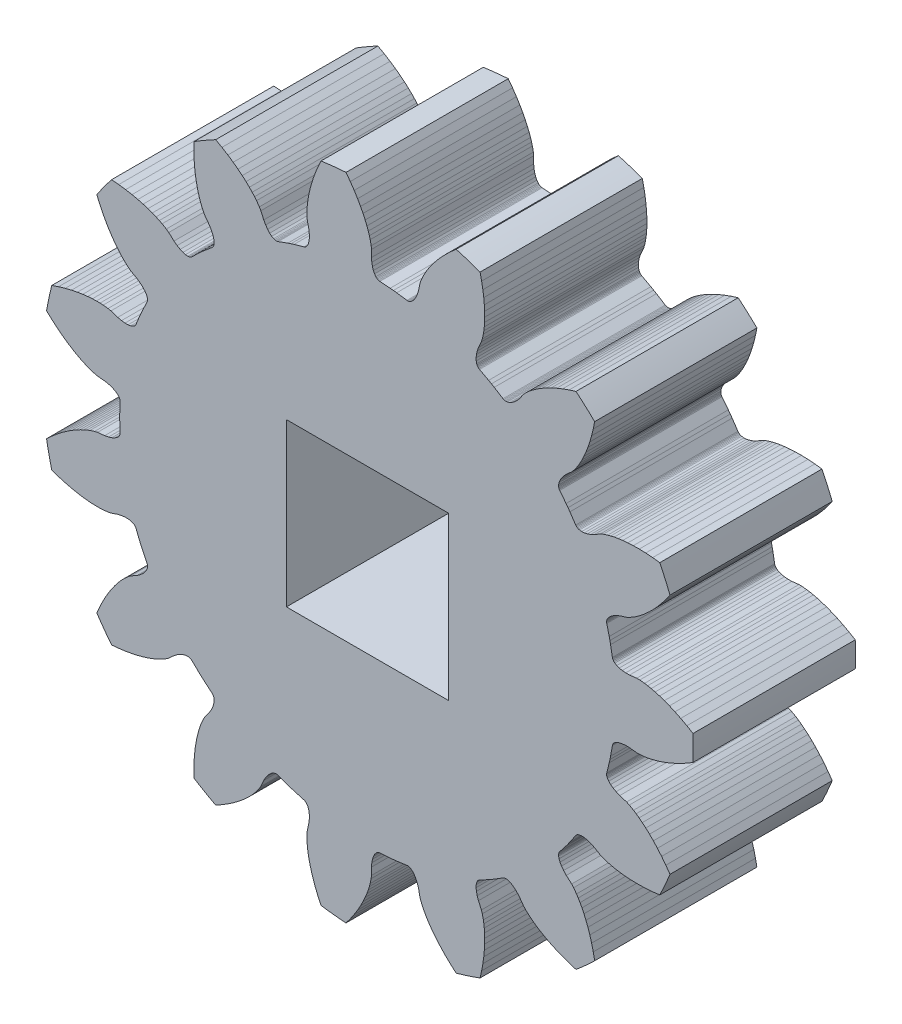
from build123d import *

# Parameters (mm, degrees)
BOSS_EXTRUDE1_DEPTH     = 3.175
CUT_EXTRUDE1_DEPTH      = 19.289183037
CUT_EXTRUDE1_DEPTH_BACK = 19.289183037
SKETCH2_W               = 6.35
SKETCH2_H               = 6.35


with BuildPart() as part:
    # Model → Boss-Extrude1 (new, symmetric)
    with BuildSketch(Plane.XY):
        with BuildLine():
            Line((11.6767396, 4.5035235), (11.5102774, 4.2884543))
            Line((11.5102774, 4.2884543), (11.3474436, 4.0953698))
            Line((11.3474436, 4.0953698), (11.189078, 3.9227721))
            Line((11.189078, 3.9227721), (11.0381832, 3.7714935))
            Line((11.0381832, 3.7714935), (10.8924568, 3.6371189))
            Line((10.8924568, 3.6371189), (10.7549211, 3.520628))
            Line((10.7549211, 3.520628), (10.6294039, 3.4230594))
            Line((10.6294039, 3.4230594), (10.5151057, 3.3415851))
            Line((10.5151057, 3.3415851), (10.4118689, 3.2743006))
            Line((10.4118689, 3.2743006), (10.2465352, 3.1803221))
            Line((10.2465352, 3.1803221), (10.1399378, 3.1308686))
            Line((10.1399378, 3.1308686), (9.8729831, 3.0466553))
            Line((9.8729831, 3.0466553), (9.731807, 2.9862021))
            Line((9.731807, 2.9862021), (9.6130244, 2.9201014))
            Line((9.6130244, 2.9201014), (9.516822, 2.8501205))
            Line((9.516822, 2.8501205), (9.4432844, 2.7780258))
            Line((9.4432844, 2.7780258), (9.3923921, 2.7055918))
            Line((9.3923921, 2.7055918), (9.3753911, 2.6698051))
            Line((9.3753911, 2.6698051), (9.3639924, 2.6345957))
            Line((9.3639924, 2.6345957), (9.3581623, 2.6001713))
            Line((9.3581623, 2.6001713), (9.3578605, 2.5667687))
            Line((9.3578605, 2.5667687), (9.3630336, 2.5345911))
            Line((9.3630336, 2.5345911), (9.460687, 2.1414942))
            Line((9.460687, 2.1414942), (9.4880317, 2.0167434))
            Line((9.4880317, 2.0167434), (9.5137918, 1.8916558))
            Line((9.5137918, 1.8916558), (9.5844679, 1.4928247))
            Line((9.5844679, 1.4928247), (9.5928298, 1.4613249))
            Line((9.5928298, 1.4613249), (9.6066916, 1.4309328))
            Line((9.6066916, 1.4309328), (9.6260194, 1.4018559))
            Line((9.6260194, 1.4018559), (9.6507535, 1.3743268))
            Line((9.6507535, 1.3743268), (9.6808405, 1.3485489))
            Line((9.6808405, 1.3485489), (9.7567944, 1.303077))
            Line((9.7567944, 1.303077), (9.853298, 1.2671256))
            Line((9.853298, 1.2671256), (9.969647, 1.2423239))
            Line((9.969647, 1.2423239), (10.1050459, 1.2302511))
            Line((10.1050459, 1.2302511), (10.2586052, 1.2324459))
            Line((10.2586052, 1.2324459), (10.5367331, 1.2640935))
            Line((10.5367331, 1.2640935), (10.6542293, 1.2622725))
            Line((10.6542293, 1.2622725), (10.8434936, 1.2436662))
            Line((10.8434936, 1.2436662), (10.9651721, 1.2241889))
            Line((10.9651721, 1.2241889), (11.1027273, 1.1962477))
            Line((11.1027273, 1.1962477), (11.2570777, 1.1581668))
            Line((11.2570777, 1.1581668), (11.4301039, 1.1076879))
            Line((11.4301039, 1.1076879), (11.6178867, 1.0442028))
            Line((11.6178867, 1.0442028), (11.8172666, 0.9673774))
            Line((11.8172666, 0.9673774), (12.0321425, 0.8741146))
            Line((12.0321425, 0.8741146), (12.2594331, 0.7639537))
            Line((12.2594331, 0.7639537), (12.4989804, 0.6351845))
            Line((12.4989804, 0.6351845), (12.740472, 0.4919755))
            ThreePointArc((12.740472, 0.4919755), (12.749967296, 0), (12.740472, -0.4919755))
            Line((12.740472, -0.4919755), (12.4989804, -0.6351845))
            Line((12.4989804, -0.6351845), (12.2594331, -0.7639537))
            Line((12.2594331, -0.7639537), (12.0321425, -0.8741146))
            Line((12.0321425, -0.8741146), (11.8172666, -0.9673774))
            Line((11.8172666, -0.9673774), (11.6178867, -1.0442028))
            Line((11.6178867, -1.0442028), (11.4301039, -1.1076879))
            Line((11.4301039, -1.1076879), (11.2570777, -1.1581668))
            Line((11.2570777, -1.1581668), (11.1027273, -1.1962477))
            Line((11.1027273, -1.1962477), (10.9651721, -1.2241889))
            Line((10.9651721, -1.2241889), (10.8434936, -1.2436662))
            Line((10.8434936, -1.2436662), (10.6542293, -1.2622725))
            Line((10.6542293, -1.2622725), (10.5367331, -1.2640935))
            Line((10.5367331, -1.2640935), (10.2586052, -1.2324459))
            Line((10.2586052, -1.2324459), (10.1050459, -1.2302511))
            Line((10.1050459, -1.2302511), (9.969647, -1.2423239))
            Line((9.969647, -1.2423239), (9.853298, -1.2671256))
            Line((9.853298, -1.2671256), (9.7567944, -1.303077))
            Line((9.7567944, -1.303077), (9.6808405, -1.3485489))
            Line((9.6808405, -1.3485489), (9.6507535, -1.3743268))
            Line((9.6507535, -1.3743268), (9.6260194, -1.4018559))
            Line((9.6260194, -1.4018559), (9.6066916, -1.4309328))
            Line((9.6066916, -1.4309328), (9.5928298, -1.4613249))
            Line((9.5928298, -1.4613249), (9.5844679, -1.4928247))
            Line((9.5844679, -1.4928247), (9.5137918, -1.8916558))
            Line((9.5137918, -1.8916558), (9.4880317, -2.0167434))
            Line((9.4880317, -2.0167434), (9.460687, -2.1414942))
            Line((9.460687, -2.1414942), (9.3630336, -2.5345911))
            Line((9.3630336, -2.5345911), (9.3578605, -2.5667687))
            Line((9.3578605, -2.5667687), (9.3581623, -2.6001713))
            Line((9.3581623, -2.6001713), (9.3639924, -2.6345957))
            Line((9.3639924, -2.6345957), (9.3753911, -2.6698051))
            Line((9.3753911, -2.6698051), (9.3923921, -2.7055918))
            Line((9.3923921, -2.7055918), (9.4432844, -2.7780258))
            Line((9.4432844, -2.7780258), (9.516822, -2.8501205))
            Line((9.516822, -2.8501205), (9.6130244, -2.9201014))
            Line((9.6130244, -2.9201014), (9.731807, -2.9862021))
            Line((9.731807, -2.9862021), (9.8729831, -3.0466553))
            Line((9.8729831, -3.0466553), (10.1399378, -3.1308686))
            Line((10.1399378, -3.1308686), (10.2465352, -3.1803221))
            Line((10.2465352, -3.1803221), (10.4118689, -3.2743006))
            Line((10.4118689, -3.2743006), (10.5151057, -3.3415851))
            Line((10.5151057, -3.3415851), (10.6294039, -3.4230594))
            Line((10.6294039, -3.4230594), (10.7549211, -3.520628))
            Line((10.7549211, -3.520628), (10.8924568, -3.6371189))
            Line((10.8924568, -3.6371189), (11.0381832, -3.7714935))
            Line((11.0381832, -3.7714935), (11.189078, -3.9227721))
            Line((11.189078, -3.9227721), (11.3474436, -4.0953698))
            Line((11.3474436, -4.0953698), (11.5102774, -4.2884543))
            Line((11.5102774, -4.2884543), (11.6767396, -4.5035235))
            Line((11.6767396, -4.5035235), (11.8391048, -4.7325748))
            ThreePointArc((11.8391048, -4.7325748), (11.647674735, -5.185878885), (11.4388959, -5.6314588))
            Line((11.4388959, -5.6314588), (11.160034, -5.6640632))
            Line((11.160034, -5.6640632), (10.8888215, -5.6842671))
            Line((10.8888215, -5.6842671), (10.6363747, -5.6924567))
            Line((10.6363747, -5.6924567), (10.4021424, -5.6902585))
            Line((10.4021424, -5.6902585), (10.1887521, -5.679347))
            Line((10.1887521, -5.679347), (9.9913823, -5.6609653))
            Line((9.9913823, -5.6609653), (9.8127834, -5.636704))
            Line((9.8127834, -5.636704), (9.6562884, -5.6087127))
            Line((9.6562884, -5.6087127), (9.5192607, -5.5782895))
            Line((9.5192607, -5.5782895), (9.4001797, -5.5465918))
            Line((9.4001797, -5.5465918), (9.2197103, -5.4866088))
            Line((9.2197103, -5.4866088), (9.1116315, -5.4404823))
            Line((9.1116315, -5.4404823), (8.8704213, -5.298446))
            Line((8.8704213, -5.298446), (8.7310306, -5.2339828))
            Line((8.7310306, -5.2339828), (8.6024271, -5.1899402))
            Line((8.6024271, -5.1899402), (8.4860492, -5.1652742))
            Line((8.4860492, -5.1652742), (8.3832661, -5.1588659))
            Line((8.3832661, -5.1588659), (8.2953836, -5.1695133))
            Line((8.2953836, -5.1695133), (8.257413, -5.1808251))
            Line((8.257413, -5.1808251), (8.2236201, -5.1959139))
            Line((8.2236201, -5.1959139), (8.1941367, -5.2146157))
            Line((8.1941367, -5.2146157), (8.1691117, -5.2367421))
            Line((8.1691117, -5.2367421), (8.1486606, -5.2621176))
            Line((8.1486606, -5.2621176), (7.9218756, -5.5977213))
            Line((7.9218756, -5.5977213), (7.8474648, -5.7015169))
            Line((7.8474648, -5.7015169), (7.7717435, -5.8043604))
            Line((7.7717435, -5.8043604), (7.5226458, -6.123753))
            Line((7.5226458, -6.123753), (7.5048321, -6.1510446))
            Line((7.5048321, -6.1510446), (7.4915217, -6.1816822))
            Line((7.4915217, -6.1816822), (7.4828461, -6.2155018))
            Line((7.4828461, -6.2155018), (7.4789384, -6.2523034))
            Line((7.4789384, -6.2523034), (7.4799138, -6.2919111))
            Line((7.4799138, -6.2919111), (7.4969447, -6.3787826))
            Line((7.4969447, -6.3787826), (7.5348011, -6.4745549))
            Line((7.5348011, -6.4745549), (7.5942226, -6.5776146))
            Line((7.5942226, -6.5776146), (7.6758502, -6.6863139))
            Line((7.6758502, -6.6863139), (7.7802325, -6.7989622))
            Line((7.7802325, -6.7989622), (7.9898551, -6.984475))
            Line((7.9898551, -6.984475), (8.0671222, -7.0730102))
            Line((8.0671222, -7.0730102), (8.1799375, -7.2261111))
            Line((8.1799375, -7.2261111), (8.246882, -7.3295686))
            Line((8.246882, -7.3295686), (8.31816, -7.4504884))
            Line((8.31816, -7.4504884), (8.3931409, -7.5906742))
            Line((8.3931409, -7.5906742), (8.4714049, -7.7530347))
            Line((8.4714049, -7.7530347), (8.5498775, -7.9350643))
            Line((8.5498775, -7.9350643), (8.6261962, -8.1346387))
            Line((8.6261962, -8.1346387), (8.7006686, -8.3567276))
            Line((8.7006686, -8.3567276), (8.7708902, -8.5993495))
            Line((8.7708902, -8.5993495), (8.8354844, -8.8635313))
            Line((8.8354844, -8.8635313), (8.8906488, -9.13882))
            ThreePointArc((8.8906488, -9.13882), (8.531393343, -9.47507223), (8.1594307, -9.7972117))
            Line((8.1594307, -9.7972117), (7.8914163, -9.713574))
            Line((7.8914163, -9.713574), (7.6354337, -9.6217191))
            Line((7.6354337, -9.6217191), (7.4014811, -9.5265213))
            Line((7.4014811, -9.5265213), (7.1883932, -9.4292423))
            Line((7.1883932, -9.4292423), (6.9978897, -9.3324805))
            Line((6.9978897, -9.3324805), (6.8250599, -9.2354105))
            Line((6.8250599, -9.2354105), (6.6717696, -9.1406039))
            Line((6.6717696, -9.1406039), (6.5401894, -9.0513803))
            Line((6.5401894, -9.0513803), (6.4273826, -8.9678532))
            Line((6.4273826, -8.9678532), (6.3314894, -8.8904613))
            Line((6.3314894, -8.8904613), (6.1910196, -8.7622605))
            Line((6.1910196, -8.7622605), (6.1110461, -8.6761623))
            Line((6.1110461, -8.6761623), (5.948461, -8.4482966))
            Line((5.948461, -8.4482966), (5.8473407, -8.3327113))
            Line((5.8473407, -8.3327113), (5.7477694, -8.2401686))
            Line((5.7477694, -8.2401686), (5.6514854, -8.1702999))
            Line((5.6514854, -8.1702999), (5.5601949, -8.12264))
            Line((5.5601949, -8.12264), (5.4755795, -8.0966219))
            Line((5.4755795, -8.0966219), (5.4362907, -8.0915117))
            Line((5.4362907, -8.0915117), (5.3992822, -8.0915512))
            Line((5.3992822, -8.0915512), (5.3647411, -8.0966441))
            Line((5.3647411, -8.0966441), (5.33288, -8.1066791))
            Line((5.33288, -8.1066791), (5.3038758, -8.1215424))
            Line((5.3038758, -8.1215424), (4.9601951, -8.3358899))
            Line((4.9601951, -8.3358899), (4.85, -8.4004464))
            Line((4.85, -8.4004464), (4.7389949, -8.4635999))
            Line((4.7389949, -8.4635999), (4.3815242, -8.6540624))
            Line((4.3815242, -8.6540624), (4.35415, -8.6717491))
            Line((4.35415, -8.6717491), (4.3295289, -8.6943241))
            Line((4.3295289, -8.6943241), (4.3078478, -8.7216912))
            Line((4.3078478, -8.7216912), (4.2893093, -8.7537217))
            Line((4.2893093, -8.7537217), (4.2740905, -8.7903019))
            Line((4.2740905, -8.7903019), (4.2543151, -8.87659))
            Line((4.2543151, -8.87659), (4.2499446, -8.9794799))
            Line((4.2499446, -8.9794799), (4.2623106, -9.0977986))
            Line((4.2623106, -9.0977986), (4.2926693, -9.2303013))
            Line((4.2926693, -9.2303013), (4.342209, -9.3756666))
            Line((4.342209, -9.3756666), (4.4582539, -9.6304023))
            Line((4.4582539, -9.6304023), (4.4928304, -9.7427105))
            Line((4.4928304, -9.7427105), (4.5336206, -9.9284613))
            Line((4.5336206, -9.9284613), (4.5526974, -10.0502032))
            Line((4.5526974, -10.0502032), (4.5686306, -10.1896603))
            Line((4.5686306, -10.1896603), (4.5801104, -10.3482239))
            Line((4.5801104, -10.3482239), (4.5855701, -10.5283805))
            Line((4.5855701, -10.5283805), (4.5832203, -10.7265905))
            Line((4.5832203, -10.7265905), (4.5717668, -10.9399523))
            Line((4.5717668, -10.9399523), (4.5494689, -11.1731313))
            Line((4.5494689, -11.1731313), (4.5149363, -11.4233391))
            Line((4.5149363, -11.4233391), (4.4664937, -11.690954))
            Line((4.4664937, -11.690954), (4.4049189, -11.9648801))
            ThreePointArc((4.4049189, -11.9648801), (3.939956558, -12.125939465), (3.4691258, -12.2689377))
            Line((3.4691258, -12.2689377), (3.258301, -12.0835196))
            Line((3.258301, -12.0835196), (3.06181, -11.8954884))
            Line((3.06181, -11.8954884), (2.8868041, -11.7133638))
            Line((2.8868041, -11.7133638), (2.7317056, -11.5378244))
            Line((2.7317056, -11.5378244), (2.5970286, -11.3719433))
            Line((2.5970286, -11.3719433), (2.4786226, -11.2129692))
            Line((2.4786226, -11.2129692), (2.3771463, -11.0640104))
            Line((2.3771463, -11.0640104), (2.2932323, -10.9289821))
            Line((2.2932323, -10.9289821), (2.2241517, -10.8067936))
            Line((2.2241517, -10.8067936), (2.168027, -10.6970892))
            Line((2.168027, -10.6970892), (2.0918454, -10.5228378))
            Line((2.0918454, -10.5228378), (2.0538053, -10.411655))
            Line((2.0538053, -10.411655), (1.9979577, -10.1373601))
            Line((1.9979577, -10.1373601), (1.9525926, -9.9906383))
            Line((1.9525926, -9.9906383), (1.8992701, -9.865597))
            Line((1.8992701, -9.865597), (1.8397285, -9.7626066))
            Line((1.8397285, -9.7626066), (1.7757154, -9.6819359))
            Line((1.7757154, -9.6819359), (1.708998, -9.623751))
            Line((1.708998, -9.623751), (1.6751844, -9.6031024))
            Line((1.6751844, -9.6031024), (1.6413594, -9.5880858))
            Line((1.6413594, -9.5880858), (1.607733, -9.5786892))
            Line((1.607733, -9.5786892), (1.5745448, -9.5748975))
            Line((1.5745448, -9.5748975), (1.5420028, -9.5766789))
            Line((1.5420028, -9.5766789), (1.1408518, -9.6327075))
            Line((1.1408518, -9.6327075), (1.0139261, -9.6468624))
            Line((1.0139261, -9.6468624), (0.886831, -9.6594062))
            Line((0.886831, -9.6594062), (0.4827972, -9.6880059))
            Line((0.4827972, -9.6880059), (0.4505959, -9.6930293))
            Line((0.4505959, -9.6930293), (0.4189213, -9.7036383))
            Line((0.4189213, -9.7036383), (0.3879834, -9.7198209))
            Line((0.3879834, -9.7198209), (0.3580197, -9.7415419))
            Line((0.3580197, -9.7415419), (0.3292381, -9.7687696))
            Line((0.3292381, -9.7687696), (0.2760759, -9.8395543))
            Line((0.2760759, -9.8395543), (0.230234, -9.9317713))
            Line((0.230234, -9.9317713), (0.1934065, -10.0448905))
            Line((0.1934065, -10.0448905), (0.1672468, -10.1782857))
            Line((0.1672468, -10.1782857), (0.1533782, -10.3312332))
            Line((0.1533782, -10.3312332), (0.1557801, -10.6111455))
            Line((0.1557801, -10.6111455), (0.1416874, -10.7278077))
            Line((0.1416874, -10.7278077), (0.1033995, -10.9140903))
            Line((0.1033995, -10.9140903), (0.0713101, -11.0330664))
            Line((0.0713101, -11.0330664), (0.0291435, -11.1669474))
            Line((0.0291435, -11.1669474), (-0.0248628, -11.3164717))
            Line((-0.0248628, -11.3164717), (-0.0931514, -11.4832735))
            Line((-0.0931514, -11.4832735), (-0.1759173, -11.6633916))
            Line((-0.1759173, -11.6633916), (-0.2731627, -11.8536488))
            Line((-0.2731627, -11.8536488), (-0.3883753, -12.0575991))
            Line((-0.3883753, -12.0575991), (-0.521691, -12.2721296))
            Line((-0.521691, -12.2721296), (-0.6747944, -12.4969046))
            Line((-0.6747944, -12.4969046), (-0.8424615, -12.7221038))
            ThreePointArc((-0.8424615, -12.7221038), (-1.332734479, -12.680121632), (-1.8210224, -12.6192529))
            Line((-1.8210224, -12.6192529), (-1.9382041, -12.3641149))
            Line((-1.9382041, -12.3641149), (-2.0412284, -12.1124198))
            Line((-2.0412284, -12.1124198), (-2.1270275, -11.8748593))
            Line((-2.1270275, -11.8748593), (-2.1973187, -11.6514119))
            Line((-2.1973187, -11.6514119), (-2.2528824, -11.4450938))
            Line((-2.2528824, -11.4450938), (-2.296391, -11.2517037))
            Line((-2.296391, -11.2517037), (-2.3285073, -11.0743489))
            Line((-2.3285073, -11.0743489), (-2.3502456, -10.9168635))
            Line((-2.3502456, -10.9168635), (-2.3636553, -10.7771412))
            Line((-2.3636553, -10.7771412), (-2.370307, -10.6540933))
            Line((-2.370307, -10.6540933), (-2.3690279, -10.4639209))
            Line((-2.3690279, -10.4639209), (-2.3585571, -10.346878))
            Line((-2.3585571, -10.346878), (-2.2980106, -10.0735819))
            Line((-2.2980106, -10.0735819), (-2.2797766, -9.9210931))
            Line((-2.2797766, -9.9210931), (-2.2776302, -9.7851741))
            Line((-2.2776302, -9.7851741), (-2.2901342, -9.6668699))
            Line((-2.2901342, -9.6668699), (-2.3158013, -9.5671371))
            Line((-2.3158013, -9.5671371), (-2.3530848, -9.4868461))
            Line((-2.3530848, -9.4868461), (-2.3755765, -9.4542294))
            Line((-2.3755765, -9.4542294), (-2.4003694, -9.4267532))
            Line((-2.4003694, -9.4267532), (-2.4272667, -9.4044919))
            Line((-2.4272667, -9.4044919), (-2.4560434, -9.3875292))
            Line((-2.4560434, -9.3875292), (-2.4864966, -9.3759205))
            Line((-2.4864966, -9.3759205), (-2.8757551, -9.2639424))
            Line((-2.8757551, -9.2639424), (-2.9974648, -9.2252482))
            Line((-2.9974648, -9.2252482), (-3.118674, -9.1850133))
            Line((-3.118674, -9.1850133), (-3.4994098, -9.0468051))
            Line((-3.4994098, -9.0468051), (-3.5308704, -9.0382968))
            Line((-3.5308704, -9.0382968), (-3.5641216, -9.0351054))
            Line((-3.5641216, -9.0351054), (-3.5989669, -9.0373053))
            Line((-3.5989669, -9.0373053), (-3.6351748, -9.0449611))
            Line((-3.6351748, -9.0449611), (-3.6725426, -9.0581283))
            Line((-3.6725426, -9.0581283), (-3.7498994, -9.1011703))
            Line((-3.7498994, -9.1011703), (-3.8292861, -9.1667692))
            Line((-3.8292861, -9.1667692), (-3.9089394, -9.2551296))
            Line((-3.9089394, -9.2551296), (-3.9870942, -9.366352))
            Line((-3.9870942, -9.366352), (-4.0619732, -9.5004357))
            Line((-4.0619732, -9.5004357), (-4.1736295, -9.7571253))
            Line((-4.1736295, -9.7571253), (-4.2339546, -9.8579694))
            Line((-4.2339546, -9.8579694), (-4.3447003, -10.012574))
            Line((-4.3447003, -10.012574), (-4.4224073, -10.1082121))
            Line((-4.4224073, -10.1082121), (-4.5153828, -10.2133678))
            Line((-4.5153828, -10.2133678), (-4.625537, -10.3279987))
            Line((-4.625537, -10.3279987), (-4.7557661, -10.4526043))
            Line((-4.7557661, -10.4526043), (-4.9046372, -10.5834864))
            Line((-4.9046372, -10.5834864), (-5.0708599, -10.7177417))
            Line((-5.0708599, -10.7177417), (-5.2590658, -10.8571984))
            Line((-5.2590658, -10.8571984), (-5.4681133, -10.9989574))
            Line((-5.4681133, -10.9989574), (-5.6994043, -11.1420268))
            Line((-5.6994043, -11.1420268), (-5.9441727, -11.2795602))
            ThreePointArc((-5.9441727, -11.2795602), (-6.374983648, -11.041795618), (-6.7962993, -10.7875847))
            Line((-6.7962993, -10.7875847), (-6.7995761, -10.5068423))
            Line((-6.7995761, -10.5068423), (-6.7913199, -10.2350037))
            Line((-6.7913199, -10.2350037), (-6.7730767, -9.9830838))
            Line((-6.7730767, -9.9830838), (-6.7464067, -9.7503643))
            Line((-6.7464067, -9.7503643), (-6.7132495, -9.5392836))
            Line((-6.7132495, -9.5392836), (-6.6743378, -9.3449164))
            Line((-6.6743378, -9.3449164), (-6.6315407, -9.1698319))
            Line((-6.6315407, -9.1698319), (-6.5873446, -9.0171201))
            Line((-6.5873446, -9.0171201), (-6.5427648, -8.8840231))
            Line((-6.5427648, -8.8840231), (-6.4987933, -8.7689078))
            Line((-6.4987933, -8.7689078), (-6.4202747, -8.5956969))
            Line((-6.4202747, -8.5956969), (-6.3631036, -8.4930318))
            Line((-6.3631036, -8.4930318), (-6.196632, -8.2679898))
            Line((-6.196632, -8.2679898), (-6.1179517, -8.1361009))
            Line((-6.1179517, -8.1361009), (-6.0607076, -8.0128056))
            Line((-6.0607076, -8.0128056), (-6.0240119, -7.8996436))
            Line((-6.0240119, -7.8996436), (-6.006895, -7.7980933))
            Line((-6.006895, -7.7980933), (-6.0082979, -7.7095793))
            Line((-6.0082979, -7.7095793), (-6.0155787, -7.6706343))
            Line((-6.0155787, -7.6706343), (-6.0270525, -7.6354494))
            Line((-6.0270525, -7.6354494), (-6.04257, -7.6041726))
            Line((-6.04257, -7.6041726), (-6.0619594, -7.5769719))
            Line((-6.0619594, -7.5769719), (-6.0850581, -7.5539803))
            Line((-6.0850581, -7.5539803), (-6.3951179, -7.2933575))
            Line((-6.3951179, -7.2933575), (-6.4905669, -7.2085048))
            Line((-6.4905669, -7.2085048), (-6.5849319, -7.1224482))
            Line((-6.5849319, -7.1224482), (-6.8765371, -6.8413295))
            Line((-6.8765371, -6.8413295), (-6.9018171, -6.8207606))
            Line((-6.9018171, -6.8207606), (-6.9308956, -6.8043206))
            Line((-6.9308956, -6.8043206), (-6.9636231, -6.7921575))
            Line((-6.9636231, -6.7921575), (-6.9998146, -6.7844243))
            Line((-6.9998146, -6.7844243), (-7.0393073, -6.7812543))
            Line((-7.0393073, -6.7812543), (-7.1274831, -6.7891113))
            Line((-7.1274831, -6.7891113), (-7.2266878, -6.8167494))
            Line((-7.2266878, -6.8167494), (-7.3353942, -6.8650727))
            Line((-7.3353942, -6.8650727), (-7.4520304, -6.934891))
            Line((-7.4520304, -6.934891), (-7.5749725, -7.0269265))
            Line((-7.5749725, -7.0269265), (-7.7813806, -7.2160094))
            Line((-7.7813806, -7.2160094), (-7.8775074, -7.2835987))
            Line((-7.8775074, -7.2835987), (-8.041562, -7.3797927))
            Line((-8.041562, -7.3797927), (-8.1514504, -7.4355561))
            Line((-8.1514504, -7.4355561), (-8.2791584, -7.4938041))
            Line((-8.2791584, -7.4938041), (-8.4264138, -7.5537209))
            Line((-8.4264138, -7.5537209), (-8.5960657, -7.6145848))
            Line((-8.5960657, -7.6145848), (-8.7853008, -7.6736003))
            Line((-8.7853008, -7.6736003), (-8.9917593, -7.7286398))
            Line((-8.9917593, -7.7286398), (-9.2204161, -7.7794895))
            Line((-9.2204161, -7.7794895), (-9.469049, -7.8239655))
            Line((-9.469049, -7.8239655), (-9.7385355, -7.8605914))
            Line((-9.7385355, -7.8605914), (-10.0180824, -7.8866781))
            ThreePointArc((-10.0180824, -7.8866781), (-10.314940206, -7.494242745), (-10.5964343, -7.090645))
            Line((-10.5964343, -7.090645), (-10.4852396, -6.8328413))
            Line((-10.4852396, -6.8328413), (-10.3671305, -6.5878625))
            Line((-10.3671305, -6.5878625), (-10.2479995, -6.3651424))
            Line((-10.2479995, -6.3651424), (-10.1289796, -6.1633903))
            Line((-10.1289796, -6.1633903), (-10.0128348, -5.9840447))
            Line((-10.0128348, -5.9840447), (-9.8982309, -5.8223082))
            Line((-9.8982309, -5.8223082), (-9.7879206, -5.6797677))
            Line((-9.7879206, -5.6797677), (-9.6854319, -5.5582347))
            Line((-9.6854319, -5.5582347), (-9.5905708, -5.4547768))
            Line((-9.5905708, -5.4547768), (-9.5035793, -5.3674986))
            Line((-9.5035793, -5.3674986), (-9.3613977, -5.2411989))
            Line((-9.3613977, -5.2411989), (-9.2674116, -5.1706632))
            Line((-9.2674116, -5.1706632), (-9.0237995, -5.0327872))
            Line((-9.0237995, -5.0327872), (-8.8982773, -4.9443029))
            Line((-8.8982773, -4.9443029), (-8.7958336, -4.8549503))
            Line((-8.7958336, -4.8549503), (-8.7162832, -4.7664971))
            Line((-8.7162832, -4.7664971), (-8.6593419, -4.6806884))
            Line((-8.6593419, -4.6806884), (-8.6246217, -4.5992563))
            Line((-8.6246217, -4.5992563), (-8.6154326, -4.5607168))
            Line((-8.6154326, -4.5607168), (-8.6116035, -4.523907))
            Line((-8.6116035, -4.523907), (-8.613058, -4.4890227))
            Line((-8.613058, -4.4890227), (-8.6197076, -4.4562872))
            Line((-8.6197076, -4.4562872), (-8.6314578, -4.4258883))
            Line((-8.6314578, -4.4258883), (-8.8087066, -4.0616849))
            Line((-8.8087066, -4.0616849), (-8.8613909, -3.9453454))
            Line((-8.8613909, -3.9453454), (-8.9125953, -3.8283471))
            Line((-8.9125953, -3.8283471), (-9.0646486, -3.4529259))
            Line((-9.0646486, -3.4529259), (-9.0793769, -3.4238529))
            Line((-9.0793769, -3.4238529), (-9.0992547, -3.397007))
            Line((-9.0992547, -3.397007), (-9.1242055, -3.3725839))
            Line((-9.1242055, -3.3725839), (-9.1541228, -3.350799))
            Line((-9.1541228, -3.350799), (-9.1889118, -3.3318398))
            Line((-9.1889118, -3.3318398), (-9.2726601, -3.3031533))
            Line((-9.2726601, -3.3031533), (-9.3745296, -3.2880517))
            Line((-9.3745296, -3.2880517), (-9.4934927, -3.2879823))
            Line((-9.4934927, -3.2879823), (-9.6284428, -3.3043244))
            Line((-9.6284428, -3.3043244), (-9.7781902, -3.3383979))
            Line((-9.7781902, -3.3383979), (-10.0436604, -3.42718))
            Line((-10.0436604, -3.42718), (-10.1589676, -3.4498276))
            Line((-10.1589676, -3.4498276), (-10.3479645, -3.4709782))
            Line((-10.3479645, -3.4709782), (-10.4710336, -3.477225))
            Line((-10.4710336, -3.477225), (-10.6113922, -3.4784936))
            Line((-10.6113922, -3.4784936), (-10.7702872, -3.4733361))
            Line((-10.7702872, -3.4733361), (-10.9500275, -3.4599345))
            Line((-10.9500275, -3.4599345), (-11.1469061, -3.4368789))
            Line((-11.1469061, -3.4368789), (-11.3579019, -3.4031857))
            Line((-11.3579019, -3.4031857), (-11.5874727, -3.3566362))
            Line((-11.5874727, -3.3566362), (-11.8327002, -3.2961389))
            Line((-11.8327002, -3.2961389), (-12.0937854, -3.2199883))
            Line((-12.0937854, -3.2199883), (-12.3597747, -3.1301177))
            ThreePointArc((-12.3597747, -3.1301177), (-12.471349951, -2.650867233), (-12.5643496, -2.1676684))
            Line((-12.5643496, -2.1676684), (-12.35791, -1.97738))
            Line((-12.35791, -1.97738), (-12.15037, -1.80162))
            Line((-12.15037, -1.80162), (-11.95095, -1.64661))
            Line((-11.95095, -1.64661), (-11.76016, -1.51071))
            Line((-11.76016, -1.51071), (-11.58111, -1.39411))
            Line((-11.58111, -1.39411), (-11.41063, -1.29297))
            Line((-11.41063, -1.29297), (-11.25188, -1.20762))
            Line((-11.25188, -1.20762), (-11.10882, -1.13828))
            Line((-11.10882, -1.13828), (-10.98008, -1.08235))
            Line((-10.98008, -1.08235), (-10.86511, -1.038))
            Line((-10.86511, -1.038), (-10.68385, -0.98045))
            Line((-10.68385, -0.98045), (-10.5693, -0.95424))
            Line((-10.5693, -0.95424), (-10.29067, -0.92737))
            Line((-10.29067, -0.92737), (-10.14001, -0.89759))
            Line((-10.14001, -0.89759), (-10.01008, -0.85763))
            Line((-10.01008, -0.85763), (-9.90143, -0.80918))
            Line((-9.90143, -0.80918), (-9.81451, -0.75395))
            Line((-9.81451, -0.75395), (-9.74967, -0.69368))
            Line((-9.74967, -0.69368), (-9.7256, -0.66221))
            Line((-9.7256, -0.66221), (-9.70713, -0.63014))
            Line((-9.70713, -0.63014), (-9.69427, -0.59768))
            Line((-9.69427, -0.59768), (-9.68703, -0.56507))
            Line((-9.68703, -0.56507), (-9.6854, -0.53252))
            Line((-9.6854, -0.53252), (-9.69919, -0.12771))
            Line((-9.69919, -0.12771), (-9.7, 0))
            Line((-9.7, 0), (-9.69919, 0.12771))
            Line((-9.69919, 0.12771), (-9.6854, 0.53252))
            Line((-9.6854, 0.53252), (-9.68703, 0.56507))
            Line((-9.68703, 0.56507), (-9.69427, 0.59768))
            Line((-9.69427, 0.59768), (-9.70713, 0.63014))
            Line((-9.70713, 0.63014), (-9.7256, 0.66221))
            Line((-9.7256, 0.66221), (-9.74967, 0.69368))
            Line((-9.74967, 0.69368), (-9.81451, 0.75395))
            Line((-9.81451, 0.75395), (-9.90143, 0.80918))
            Line((-9.90143, 0.80918), (-10.01008, 0.85763))
            Line((-10.01008, 0.85763), (-10.14001, 0.89759))
            Line((-10.14001, 0.89759), (-10.29067, 0.92737))
            Line((-10.29067, 0.92737), (-10.5693, 0.95424))
            Line((-10.5693, 0.95424), (-10.68385, 0.98045))
            Line((-10.68385, 0.98045), (-10.86511, 1.038))
            Line((-10.86511, 1.038), (-10.98008, 1.08235))
            Line((-10.98008, 1.08235), (-11.10882, 1.13828))
            Line((-11.10882, 1.13828), (-11.25188, 1.20762))
            Line((-11.25188, 1.20762), (-11.41063, 1.29297))
            Line((-11.41063, 1.29297), (-11.58111, 1.39411))
            Line((-11.58111, 1.39411), (-11.76016, 1.51071))
            Line((-11.76016, 1.51071), (-11.95095, 1.64661))
            Line((-11.95095, 1.64661), (-12.15037, 1.80162))
            Line((-12.15037, 1.80162), (-12.35791, 1.97738))
            Line((-12.35791, 1.97738), (-12.5643496, 2.1676684))
            ThreePointArc((-12.5643496, 2.1676684), (-12.471349951, 2.650867233), (-12.3597747, 3.1301177))
            Line((-12.3597747, 3.1301177), (-12.0937854, 3.2199883))
            Line((-12.0937854, 3.2199883), (-11.8327002, 3.2961389))
            Line((-11.8327002, 3.2961389), (-11.5874727, 3.3566362))
            Line((-11.5874727, 3.3566362), (-11.3579019, 3.4031857))
            Line((-11.3579019, 3.4031857), (-11.1469061, 3.4368789))
            Line((-11.1469061, 3.4368789), (-10.9500275, 3.4599345))
            Line((-10.9500275, 3.4599345), (-10.7702872, 3.4733361))
            Line((-10.7702872, 3.4733361), (-10.6113922, 3.4784936))
            Line((-10.6113922, 3.4784936), (-10.4710336, 3.477225))
            Line((-10.4710336, 3.477225), (-10.3479645, 3.4709782))
            Line((-10.3479645, 3.4709782), (-10.1589676, 3.4498276))
            Line((-10.1589676, 3.4498276), (-10.0436604, 3.42718))
            Line((-10.0436604, 3.42718), (-9.7781902, 3.3383979))
            Line((-9.7781902, 3.3383979), (-9.6284428, 3.3043244))
            Line((-9.6284428, 3.3043244), (-9.4934927, 3.2879823))
            Line((-9.4934927, 3.2879823), (-9.3745296, 3.2880517))
            Line((-9.3745296, 3.2880517), (-9.2726601, 3.3031533))
            Line((-9.2726601, 3.3031533), (-9.1889118, 3.3318398))
            Line((-9.1889118, 3.3318398), (-9.1541228, 3.350799))
            Line((-9.1541228, 3.350799), (-9.1242055, 3.3725839))
            Line((-9.1242055, 3.3725839), (-9.0992547, 3.397007))
            Line((-9.0992547, 3.397007), (-9.0793769, 3.4238529))
            Line((-9.0793769, 3.4238529), (-9.0646486, 3.4529259))
            Line((-9.0646486, 3.4529259), (-8.9125953, 3.8283471))
            Line((-8.9125953, 3.8283471), (-8.8613909, 3.9453454))
            Line((-8.8613909, 3.9453454), (-8.8087066, 4.0616849))
            Line((-8.8087066, 4.0616849), (-8.6314578, 4.4258883))
            Line((-8.6314578, 4.4258883), (-8.6197076, 4.4562872))
            Line((-8.6197076, 4.4562872), (-8.613058, 4.4890227))
            Line((-8.613058, 4.4890227), (-8.6116035, 4.523907))
            Line((-8.6116035, 4.523907), (-8.6154326, 4.5607168))
            Line((-8.6154326, 4.5607168), (-8.6246217, 4.5992563))
            Line((-8.6246217, 4.5992563), (-8.6593419, 4.6806884))
            Line((-8.6593419, 4.6806884), (-8.7162832, 4.7664971))
            Line((-8.7162832, 4.7664971), (-8.7958336, 4.8549503))
            Line((-8.7958336, 4.8549503), (-8.8982773, 4.9443029))
            Line((-8.8982773, 4.9443029), (-9.0237995, 5.0327872))
            Line((-9.0237995, 5.0327872), (-9.2674116, 5.1706632))
            Line((-9.2674116, 5.1706632), (-9.3613977, 5.2411989))
            Line((-9.3613977, 5.2411989), (-9.5035793, 5.3674986))
            Line((-9.5035793, 5.3674986), (-9.5905708, 5.4547768))
            Line((-9.5905708, 5.4547768), (-9.6854319, 5.5582347))
            Line((-9.6854319, 5.5582347), (-9.7879206, 5.6797677))
            Line((-9.7879206, 5.6797677), (-9.8982309, 5.8223082))
            Line((-9.8982309, 5.8223082), (-10.0128348, 5.9840447))
            Line((-10.0128348, 5.9840447), (-10.1289796, 6.1633903))
            Line((-10.1289796, 6.1633903), (-10.2479995, 6.3651424))
            Line((-10.2479995, 6.3651424), (-10.3671305, 6.5878625))
            Line((-10.3671305, 6.5878625), (-10.4852396, 6.8328413))
            Line((-10.4852396, 6.8328413), (-10.5964343, 7.090645))
            ThreePointArc((-10.5964343, 7.090645), (-10.314940206, 7.494242745), (-10.0180824, 7.8866781))
            Line((-10.0180824, 7.8866781), (-9.7385355, 7.8605914))
            Line((-9.7385355, 7.8605914), (-9.469049, 7.8239655))
            Line((-9.469049, 7.8239655), (-9.2204161, 7.7794895))
            Line((-9.2204161, 7.7794895), (-8.9917593, 7.7286398))
            Line((-8.9917593, 7.7286398), (-8.7853008, 7.6736003))
            Line((-8.7853008, 7.6736003), (-8.5960657, 7.6145848))
            Line((-8.5960657, 7.6145848), (-8.4264138, 7.5537209))
            Line((-8.4264138, 7.5537209), (-8.2791584, 7.4938041))
            Line((-8.2791584, 7.4938041), (-8.1514504, 7.4355561))
            Line((-8.1514504, 7.4355561), (-8.041562, 7.3797927))
            Line((-8.041562, 7.3797927), (-7.8775074, 7.2835987))
            Line((-7.8775074, 7.2835987), (-7.7813806, 7.2160094))
            Line((-7.7813806, 7.2160094), (-7.5749725, 7.0269265))
            Line((-7.5749725, 7.0269265), (-7.4520304, 6.934891))
            Line((-7.4520304, 6.934891), (-7.3353942, 6.8650727))
            Line((-7.3353942, 6.8650727), (-7.2266878, 6.8167494))
            Line((-7.2266878, 6.8167494), (-7.1274831, 6.7891113))
            Line((-7.1274831, 6.7891113), (-7.0393073, 6.7812543))
            Line((-7.0393073, 6.7812543), (-6.9998146, 6.7844243))
            Line((-6.9998146, 6.7844243), (-6.9636231, 6.7921575))
            Line((-6.9636231, 6.7921575), (-6.9308956, 6.8043206))
            Line((-6.9308956, 6.8043206), (-6.9018171, 6.8207606))
            Line((-6.9018171, 6.8207606), (-6.8765371, 6.8413295))
            Line((-6.8765371, 6.8413295), (-6.5849319, 7.1224482))
            Line((-6.5849319, 7.1224482), (-6.4905669, 7.2085048))
            Line((-6.4905669, 7.2085048), (-6.3951179, 7.2933575))
            Line((-6.3951179, 7.2933575), (-6.0850581, 7.5539803))
            Line((-6.0850581, 7.5539803), (-6.0619594, 7.5769719))
            Line((-6.0619594, 7.5769719), (-6.04257, 7.6041726))
            Line((-6.04257, 7.6041726), (-6.0270525, 7.6354494))
            Line((-6.0270525, 7.6354494), (-6.0155787, 7.6706343))
            Line((-6.0155787, 7.6706343), (-6.0082979, 7.7095793))
            Line((-6.0082979, 7.7095793), (-6.006895, 7.7980933))
            Line((-6.006895, 7.7980933), (-6.0240119, 7.8996436))
            Line((-6.0240119, 7.8996436), (-6.0607076, 8.0128056))
            Line((-6.0607076, 8.0128056), (-6.1179517, 8.1361009))
            Line((-6.1179517, 8.1361009), (-6.196632, 8.2679898))
            Line((-6.196632, 8.2679898), (-6.3631036, 8.4930318))
            Line((-6.3631036, 8.4930318), (-6.4202747, 8.5956969))
            Line((-6.4202747, 8.5956969), (-6.4987933, 8.7689078))
            Line((-6.4987933, 8.7689078), (-6.5427648, 8.8840231))
            Line((-6.5427648, 8.8840231), (-6.5873446, 9.0171201))
            Line((-6.5873446, 9.0171201), (-6.6315407, 9.1698319))
            Line((-6.6315407, 9.1698319), (-6.6743378, 9.3449164))
            Line((-6.6743378, 9.3449164), (-6.7132495, 9.5392836))
            Line((-6.7132495, 9.5392836), (-6.7464067, 9.7503643))
            Line((-6.7464067, 9.7503643), (-6.7730767, 9.9830838))
            Line((-6.7730767, 9.9830838), (-6.7913199, 10.2350037))
            Line((-6.7913199, 10.2350037), (-6.7995761, 10.5068423))
            Line((-6.7995761, 10.5068423), (-6.7962993, 10.7875847))
            ThreePointArc((-6.7962993, 10.7875847), (-6.374983648, 11.041795618), (-5.9441727, 11.2795602))
            Line((-5.9441727, 11.2795602), (-5.6994043, 11.1420268))
            Line((-5.6994043, 11.1420268), (-5.4681133, 10.9989574))
            Line((-5.4681133, 10.9989574), (-5.2590658, 10.8571984))
            Line((-5.2590658, 10.8571984), (-5.0708599, 10.7177417))
            Line((-5.0708599, 10.7177417), (-4.9046372, 10.5834864))
            Line((-4.9046372, 10.5834864), (-4.7557661, 10.4526043))
            Line((-4.7557661, 10.4526043), (-4.625537, 10.3279987))
            Line((-4.625537, 10.3279987), (-4.5153828, 10.2133678))
            Line((-4.5153828, 10.2133678), (-4.4224073, 10.1082121))
            Line((-4.4224073, 10.1082121), (-4.3447003, 10.012574))
            Line((-4.3447003, 10.012574), (-4.2339546, 9.8579694))
            Line((-4.2339546, 9.8579694), (-4.1736295, 9.7571253))
            Line((-4.1736295, 9.7571253), (-4.0619732, 9.5004357))
            Line((-4.0619732, 9.5004357), (-3.9870942, 9.366352))
            Line((-3.9870942, 9.366352), (-3.9089394, 9.2551296))
            Line((-3.9089394, 9.2551296), (-3.8292861, 9.1667692))
            Line((-3.8292861, 9.1667692), (-3.7498994, 9.1011703))
            Line((-3.7498994, 9.1011703), (-3.6725426, 9.0581283))
            Line((-3.6725426, 9.0581283), (-3.6351748, 9.0449611))
            Line((-3.6351748, 9.0449611), (-3.5989669, 9.0373053))
            Line((-3.5989669, 9.0373053), (-3.5641216, 9.0351054))
            Line((-3.5641216, 9.0351054), (-3.5308704, 9.0382968))
            Line((-3.5308704, 9.0382968), (-3.4994098, 9.0468051))
            Line((-3.4994098, 9.0468051), (-3.118674, 9.1850133))
            Line((-3.118674, 9.1850133), (-2.9974648, 9.2252482))
            Line((-2.9974648, 9.2252482), (-2.8757551, 9.2639424))
            Line((-2.8757551, 9.2639424), (-2.4864966, 9.3759205))
            Line((-2.4864966, 9.3759205), (-2.4560434, 9.3875292))
            Line((-2.4560434, 9.3875292), (-2.4272667, 9.4044919))
            Line((-2.4272667, 9.4044919), (-2.4003694, 9.4267532))
            Line((-2.4003694, 9.4267532), (-2.3755765, 9.4542294))
            Line((-2.3755765, 9.4542294), (-2.3530848, 9.4868461))
            Line((-2.3530848, 9.4868461), (-2.3158013, 9.5671371))
            Line((-2.3158013, 9.5671371), (-2.2901342, 9.6668699))
            Line((-2.2901342, 9.6668699), (-2.2776302, 9.7851741))
            Line((-2.2776302, 9.7851741), (-2.2797766, 9.9210931))
            Line((-2.2797766, 9.9210931), (-2.2980106, 10.0735819))
            Line((-2.2980106, 10.0735819), (-2.3585571, 10.346878))
            Line((-2.3585571, 10.346878), (-2.3690279, 10.4639209))
            Line((-2.3690279, 10.4639209), (-2.370307, 10.6540933))
            Line((-2.370307, 10.6540933), (-2.3636553, 10.7771412))
            Line((-2.3636553, 10.7771412), (-2.3502456, 10.9168635))
            Line((-2.3502456, 10.9168635), (-2.3285073, 11.0743489))
            Line((-2.3285073, 11.0743489), (-2.296391, 11.2517037))
            Line((-2.296391, 11.2517037), (-2.2528824, 11.4450938))
            Line((-2.2528824, 11.4450938), (-2.1973187, 11.6514119))
            Line((-2.1973187, 11.6514119), (-2.1270275, 11.8748593))
            Line((-2.1270275, 11.8748593), (-2.0412284, 12.1124198))
            Line((-2.0412284, 12.1124198), (-1.9382041, 12.3641149))
            Line((-1.9382041, 12.3641149), (-1.8210224, 12.6192529))
            ThreePointArc((-1.8210224, 12.6192529), (-1.332734479, 12.680121632), (-0.8424615, 12.7221038))
            Line((-0.8424615, 12.7221038), (-0.6747944, 12.4969046))
            Line((-0.6747944, 12.4969046), (-0.521691, 12.2721296))
            Line((-0.521691, 12.2721296), (-0.3883753, 12.0575991))
            Line((-0.3883753, 12.0575991), (-0.2731627, 11.8536488))
            Line((-0.2731627, 11.8536488), (-0.1759173, 11.6633916))
            Line((-0.1759173, 11.6633916), (-0.0931514, 11.4832735))
            Line((-0.0931514, 11.4832735), (-0.0248628, 11.3164717))
            Line((-0.0248628, 11.3164717), (0.0291435, 11.1669474))
            Line((0.0291435, 11.1669474), (0.0713101, 11.0330664))
            Line((0.0713101, 11.0330664), (0.1033995, 10.9140903))
            Line((0.1033995, 10.9140903), (0.1416874, 10.7278077))
            Line((0.1416874, 10.7278077), (0.1557801, 10.6111455))
            Line((0.1557801, 10.6111455), (0.1533782, 10.3312332))
            Line((0.1533782, 10.3312332), (0.1672468, 10.1782857))
            Line((0.1672468, 10.1782857), (0.1934065, 10.0448905))
            Line((0.1934065, 10.0448905), (0.230234, 9.9317713))
            Line((0.230234, 9.9317713), (0.2760759, 9.8395543))
            Line((0.2760759, 9.8395543), (0.3292381, 9.7687696))
            Line((0.3292381, 9.7687696), (0.3580197, 9.7415419))
            Line((0.3580197, 9.7415419), (0.3879834, 9.7198209))
            Line((0.3879834, 9.7198209), (0.4189213, 9.7036383))
            Line((0.4189213, 9.7036383), (0.4505959, 9.6930293))
            Line((0.4505959, 9.6930293), (0.4827972, 9.6880059))
            Line((0.4827972, 9.6880059), (0.886831, 9.6594062))
            Line((0.886831, 9.6594062), (1.0139261, 9.6468624))
            Line((1.0139261, 9.6468624), (1.1408518, 9.6327075))
            Line((1.1408518, 9.6327075), (1.5420028, 9.5766789))
            Line((1.5420028, 9.5766789), (1.5745448, 9.5748975))
            Line((1.5745448, 9.5748975), (1.607733, 9.5786892))
            Line((1.607733, 9.5786892), (1.6413594, 9.5880858))
            Line((1.6413594, 9.5880858), (1.6751844, 9.6031024))
            Line((1.6751844, 9.6031024), (1.708998, 9.623751))
            Line((1.708998, 9.623751), (1.7757154, 9.6819359))
            Line((1.7757154, 9.6819359), (1.8397285, 9.7626066))
            Line((1.8397285, 9.7626066), (1.8992701, 9.865597))
            Line((1.8992701, 9.865597), (1.9525926, 9.9906383))
            Line((1.9525926, 9.9906383), (1.9979577, 10.1373601))
            Line((1.9979577, 10.1373601), (2.0538053, 10.411655))
            Line((2.0538053, 10.411655), (2.0918454, 10.5228378))
            Line((2.0918454, 10.5228378), (2.168027, 10.6970892))
            Line((2.168027, 10.6970892), (2.2241517, 10.8067936))
            Line((2.2241517, 10.8067936), (2.2932323, 10.9289821))
            Line((2.2932323, 10.9289821), (2.3771463, 11.0640104))
            Line((2.3771463, 11.0640104), (2.4786226, 11.2129692))
            Line((2.4786226, 11.2129692), (2.5970286, 11.3719433))
            Line((2.5970286, 11.3719433), (2.7317056, 11.5378244))
            Line((2.7317056, 11.5378244), (2.8868041, 11.7133638))
            Line((2.8868041, 11.7133638), (3.06181, 11.8954884))
            Line((3.06181, 11.8954884), (3.258301, 12.0835196))
            Line((3.258301, 12.0835196), (3.4691258, 12.2689377))
            ThreePointArc((3.4691258, 12.2689377), (3.939956558, 12.125939465), (4.4049189, 11.9648801))
            Line((4.4049189, 11.9648801), (4.4664937, 11.690954))
            Line((4.4664937, 11.690954), (4.5149363, 11.4233391))
            Line((4.5149363, 11.4233391), (4.5494689, 11.1731313))
            Line((4.5494689, 11.1731313), (4.5717668, 10.9399523))
            Line((4.5717668, 10.9399523), (4.5832203, 10.7265905))
            Line((4.5832203, 10.7265905), (4.5855701, 10.5283805))
            Line((4.5855701, 10.5283805), (4.5801104, 10.3482239))
            Line((4.5801104, 10.3482239), (4.5686306, 10.1896603))
            Line((4.5686306, 10.1896603), (4.5526974, 10.0502032))
            Line((4.5526974, 10.0502032), (4.5336206, 9.9284613))
            Line((4.5336206, 9.9284613), (4.4928304, 9.7427105))
            Line((4.4928304, 9.7427105), (4.4582539, 9.6304023))
            Line((4.4582539, 9.6304023), (4.342209, 9.3756666))
            Line((4.342209, 9.3756666), (4.2926693, 9.2303013))
            Line((4.2926693, 9.2303013), (4.2623106, 9.0977986))
            Line((4.2623106, 9.0977986), (4.2499446, 8.9794799))
            Line((4.2499446, 8.9794799), (4.2543151, 8.87659))
            Line((4.2543151, 8.87659), (4.2740905, 8.7903019))
            Line((4.2740905, 8.7903019), (4.2893093, 8.7537217))
            Line((4.2893093, 8.7537217), (4.3078478, 8.7216912))
            Line((4.3078478, 8.7216912), (4.3295289, 8.6943241))
            Line((4.3295289, 8.6943241), (4.35415, 8.6717491))
            Line((4.35415, 8.6717491), (4.3815242, 8.6540624))
            Line((4.3815242, 8.6540624), (4.7389949, 8.4635999))
            Line((4.7389949, 8.4635999), (4.85, 8.4004464))
            Line((4.85, 8.4004464), (4.9601951, 8.3358899))
            Line((4.9601951, 8.3358899), (5.3038758, 8.1215424))
            Line((5.3038758, 8.1215424), (5.33288, 8.1066791))
            Line((5.33288, 8.1066791), (5.3647411, 8.0966441))
            Line((5.3647411, 8.0966441), (5.3992822, 8.0915512))
            Line((5.3992822, 8.0915512), (5.4362907, 8.0915117))
            Line((5.4362907, 8.0915117), (5.4755795, 8.0966219))
            Line((5.4755795, 8.0966219), (5.5601949, 8.12264))
            Line((5.5601949, 8.12264), (5.6514854, 8.1702999))
            Line((5.6514854, 8.1702999), (5.7477694, 8.2401686))
            Line((5.7477694, 8.2401686), (5.8473407, 8.3327113))
            Line((5.8473407, 8.3327113), (5.948461, 8.4482966))
            Line((5.948461, 8.4482966), (6.1110461, 8.6761623))
            Line((6.1110461, 8.6761623), (6.1910196, 8.7622605))
            Line((6.1910196, 8.7622605), (6.3314894, 8.8904613))
            Line((6.3314894, 8.8904613), (6.4273826, 8.9678532))
            Line((6.4273826, 8.9678532), (6.5401894, 9.0513803))
            Line((6.5401894, 9.0513803), (6.6717696, 9.1406039))
            Line((6.6717696, 9.1406039), (6.8250599, 9.2354105))
            Line((6.8250599, 9.2354105), (6.9978897, 9.3324805))
            Line((6.9978897, 9.3324805), (7.1883932, 9.4292423))
            Line((7.1883932, 9.4292423), (7.4014811, 9.5265213))
            Line((7.4014811, 9.5265213), (7.6354337, 9.6217191))
            Line((7.6354337, 9.6217191), (7.8914163, 9.713574))
            Line((7.8914163, 9.713574), (8.1594307, 9.7972117))
            ThreePointArc((8.1594307, 9.7972117), (8.531393343, 9.47507223), (8.8906488, 9.13882))
            Line((8.8906488, 9.13882), (8.8354844, 8.8635313))
            Line((8.8354844, 8.8635313), (8.7708902, 8.5993495))
            Line((8.7708902, 8.5993495), (8.7006686, 8.3567276))
            Line((8.7006686, 8.3567276), (8.6261962, 8.1346387))
            Line((8.6261962, 8.1346387), (8.5498775, 7.9350643))
            Line((8.5498775, 7.9350643), (8.4714049, 7.7530347))
            Line((8.4714049, 7.7530347), (8.3931409, 7.5906742))
            Line((8.3931409, 7.5906742), (8.31816, 7.4504884))
            Line((8.31816, 7.4504884), (8.246882, 7.3295686))
            Line((8.246882, 7.3295686), (8.1799375, 7.2261111))
            Line((8.1799375, 7.2261111), (8.0671222, 7.0730102))
            Line((8.0671222, 7.0730102), (7.9898551, 6.984475))
            Line((7.9898551, 6.984475), (7.7802325, 6.7989622))
            Line((7.7802325, 6.7989622), (7.6758502, 6.6863139))
            Line((7.6758502, 6.6863139), (7.5942226, 6.5776146))
            Line((7.5942226, 6.5776146), (7.5348011, 6.4745549))
            Line((7.5348011, 6.4745549), (7.4969447, 6.3787826))
            Line((7.4969447, 6.3787826), (7.4799138, 6.2919111))
            Line((7.4799138, 6.2919111), (7.4789384, 6.2523034))
            Line((7.4789384, 6.2523034), (7.4828461, 6.2155018))
            Line((7.4828461, 6.2155018), (7.4915217, 6.1816822))
            Line((7.4915217, 6.1816822), (7.5048321, 6.1510446))
            Line((7.5048321, 6.1510446), (7.5226458, 6.123753))
            Line((7.5226458, 6.123753), (7.7717435, 5.8043604))
            Line((7.7717435, 5.8043604), (7.8474648, 5.7015169))
            Line((7.8474648, 5.7015169), (7.9218756, 5.5977213))
            Line((7.9218756, 5.5977213), (8.1486606, 5.2621176))
            Line((8.1486606, 5.2621176), (8.1691117, 5.2367421))
            Line((8.1691117, 5.2367421), (8.1941367, 5.2146157))
            Line((8.1941367, 5.2146157), (8.2236201, 5.1959139))
            Line((8.2236201, 5.1959139), (8.257413, 5.1808251))
            Line((8.257413, 5.1808251), (8.2953836, 5.1695133))
            Line((8.2953836, 5.1695133), (8.3832661, 5.1588659))
            Line((8.3832661, 5.1588659), (8.4860492, 5.1652742))
            Line((8.4860492, 5.1652742), (8.6024271, 5.1899402))
            Line((8.6024271, 5.1899402), (8.7310306, 5.2339828))
            Line((8.7310306, 5.2339828), (8.8704213, 5.298446))
            Line((8.8704213, 5.298446), (9.1116315, 5.4404823))
            Line((9.1116315, 5.4404823), (9.2197103, 5.4866088))
            Line((9.2197103, 5.4866088), (9.4001797, 5.5465918))
            Line((9.4001797, 5.5465918), (9.5192607, 5.5782895))
            Line((9.5192607, 5.5782895), (9.6562884, 5.6087127))
            Line((9.6562884, 5.6087127), (9.8127834, 5.636704))
            Line((9.8127834, 5.636704), (9.9913823, 5.6609653))
            Line((9.9913823, 5.6609653), (10.1887521, 5.679347))
            Line((10.1887521, 5.679347), (10.4021424, 5.6902585))
            Line((10.4021424, 5.6902585), (10.6363747, 5.6924567))
            Line((10.6363747, 5.6924567), (10.8888215, 5.6842671))
            Line((10.8888215, 5.6842671), (11.160034, 5.6640632))
            Line((11.160034, 5.6640632), (11.4388959, 5.6314588))
            ThreePointArc((11.4388959, 5.6314588), (11.647674735, 5.185878885), (11.8391048, 4.7325748))
            Line((11.8391048, 4.7325748), (11.6767396, 4.5035235))
        make_face()
    extrude(amount=BOSS_EXTRUDE1_DEPTH, both=True)

    # Sketch2 → Cut-Extrude1 (cut, two sides: drawn at the far end of the back side and taken through both)
    with BuildSketch(Plane.XY.offset(-CUT_EXTRUDE1_DEPTH_BACK)):
        Rectangle(SKETCH2_W, SKETCH2_H)
    extrude(amount=CUT_EXTRUDE1_DEPTH + CUT_EXTRUDE1_DEPTH_BACK, mode=Mode.SUBTRACT)


solid = part.part
